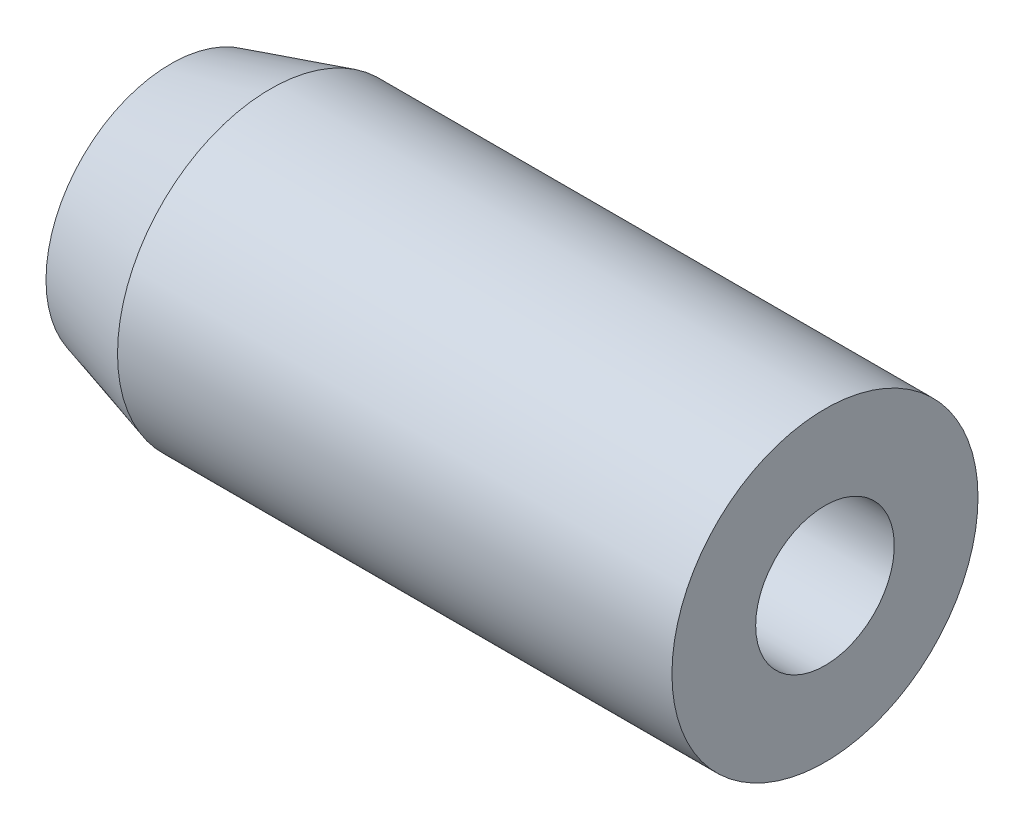
from build123d import *


with BuildPart() as part:
    # Sketch1 → Revolve1 (revolve)
    with BuildSketch(Plane(origin=(0, 0, 0), x_dir=(1, 0, 0), z_dir=(0, 1, 0))):
        Polygon((0, 1.5875), (0, 2.8575), (2.286, 3.5052), (14.986, 3.5052), (14.986, 1.5875), align=None)
    revolve(axis=Axis((0, 0, 0), (1, 0, 0)))


solid = part.part
